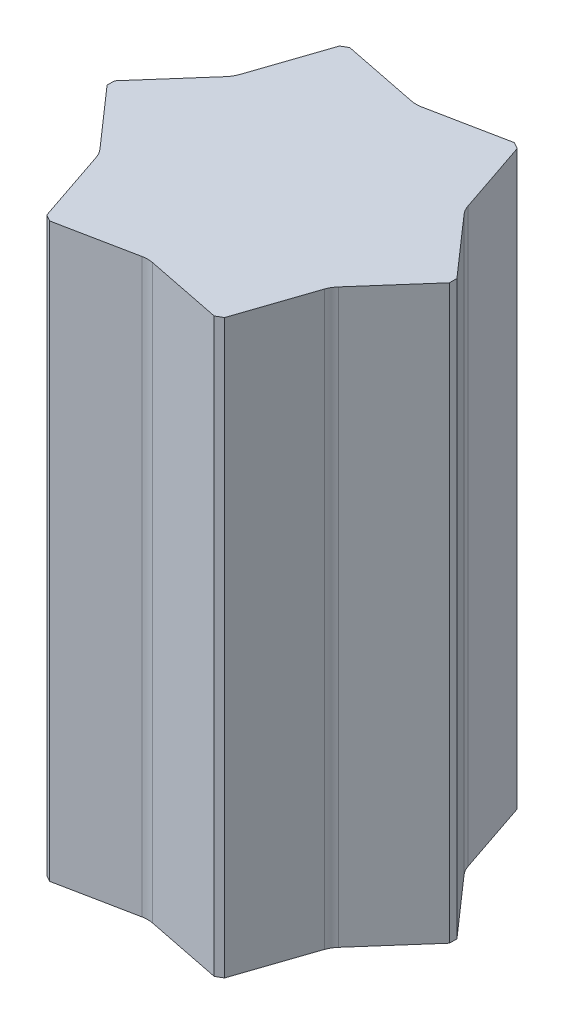
from build123d import *

# Parameters (mm, degrees)
EXTRUDE_1_DEPTH          = 660
CUT_EXTRUDE_1_DEPTH      = 661
CUT_EXTRUDE_1_DEPTH_BACK = 661
SHELL_1_T                = 10


with BuildPart() as part:
    # 草图1 → 凸台-拉伸1 (new body, symmetric)
    with BuildSketch(Plane(origin=(0, 0, 0), x_dir=(1, 0, 0), z_dir=(0, 1, 0))):
        Polygon((395, 8.660254038), (205, 337.749907476), (190, 346.410161514), (-190, 346.410161514), (-205, 337.749907476), (-395, 8.660254038), (-395, -8.660254038), (-205, -337.749907476), (-190, -346.410161514), (190, -346.410161514), (205, -337.749907476), (395, -8.660254038), align=None)
    extrude(amount=EXTRUDE_1_DEPTH, both=True)

    # 草图4 → 切除-拉伸1 (cut, two sides)
    with BuildSketch(Plane(origin=(0, 0, 0), x_dir=(1, 0, 0), z_dir=(0, 1, 0))) as cut_extrude_1_sk:
        with BuildLine():
            Line((190, 369.620348729), (190, 346.410161514))
            Line((190, 346.410161514), (11.76, 310.784114995))
            ThreePointArc((11.76, 310.784114995), (0, 309.620348729), (-11.76, 310.784114995))
            Line((-11.76, 310.784114995), (-190, 346.410161514))
            Line((-190, 346.410161514), (-190, 369.620348729))
            Line((-190, 369.620348729), (-190, 392.830535944))
            Line((-190, 392.830535944), (-11.76, 428.456582463))
            ThreePointArc((-11.76, 428.456582463), (0, 429.620348729), (11.76, 428.456582463))
            Line((11.76, 428.456582463), (190, 392.830535944))
            Line((190, 392.830535944), (190, 369.620348729))
        make_face()
        with BuildLine():
            Line((415.100611755, 20.265347645), (395, 8.660254038))
            Line((395, 8.660254038), (275.026938678, 145.207598749))
            ThreePointArc((275.026938678, 145.207598749), (268.139087528, 154.810174364), (263.266938678, 165.576516246))
            Line((263.266938678, 165.576516246), (205, 337.749907476))
            Line((205, 337.749907476), (225.100611755, 349.355001084))
            Line((225.100611755, 349.355001084), (245.20122351, 360.960094691))
            Line((245.20122351, 360.960094691), (365.174284832, 224.41274998))
            ThreePointArc((365.174284832, 224.41274998), (372.062135982, 214.810174364), (376.934284832, 204.043832483))
            Line((376.934284832, 204.043832483), (435.20122351, 31.870441253))
            Line((435.20122351, 31.870441253), (415.100611755, 20.265347645))
        make_face()
        with BuildLine():
            Line((225.100611755, -349.355001084), (205, -337.749907476))
            Line((205, -337.749907476), (263.266938678, -165.576516246))
            ThreePointArc((263.266938678, -165.576516246), (268.139087528, -154.810174364), (275.026938678, -145.207598749))
            Line((275.026938678, -145.207598749), (395, -8.660254038))
            Line((395, -8.660254038), (415.100611755, -20.265347645))
            Line((415.100611755, -20.265347645), (435.20122351, -31.870441253))
            Line((435.20122351, -31.870441253), (376.934284832, -204.043832483))
            ThreePointArc((376.934284832, -204.043832483), (372.062135982, -214.810174364), (365.174284832, -224.41274998))
            Line((365.174284832, -224.41274998), (245.20122351, -360.960094691))
            Line((245.20122351, -360.960094691), (225.100611755, -349.355001084))
        make_face()
        with BuildLine():
            Line((-190, -369.620348729), (-190, -346.410161514))
            Line((-190, -346.410161514), (-11.76, -310.784114995))
            ThreePointArc((-11.76, -310.784114995), (0, -309.620348729), (11.76, -310.784114995))
            Line((11.76, -310.784114995), (190, -346.410161514))
            Line((190, -346.410161514), (190, -369.620348729))
            Line((190, -369.620348729), (190, -392.830535944))
            Line((190, -392.830535944), (11.76, -428.456582463))
            ThreePointArc((11.76, -428.456582463), (0, -429.620348729), (-11.76, -428.456582463))
            Line((-11.76, -428.456582463), (-190, -392.830535944))
            Line((-190, -392.830535944), (-190, -369.620348729))
        make_face()
        with BuildLine():
            Line((-415.100611755, -20.265347645), (-395, -8.660254038))
            Line((-395, -8.660254038), (-275.026938678, -145.207598749))
            ThreePointArc((-275.026938678, -145.207598749), (-268.139087528, -154.810174364), (-263.266938678, -165.576516246))
            Line((-263.266938678, -165.576516246), (-205, -337.749907476))
            Line((-205, -337.749907476), (-225.100611755, -349.355001084))
            Line((-225.100611755, -349.355001084), (-245.20122351, -360.960094691))
            Line((-245.20122351, -360.960094691), (-365.174284832, -224.41274998))
            ThreePointArc((-365.174284832, -224.41274998), (-372.062135982, -214.810174364), (-376.934284832, -204.043832483))
            Line((-376.934284832, -204.043832483), (-435.20122351, -31.870441253))
            Line((-435.20122351, -31.870441253), (-415.100611755, -20.265347645))
        make_face()
        with BuildLine():
            Line((-225.100611755, 349.355001084), (-205, 337.749907476))
            Line((-205, 337.749907476), (-263.266938678, 165.576516246))
            ThreePointArc((-263.266938678, 165.576516246), (-268.139087528, 154.810174364), (-275.026938678, 145.207598749))
            Line((-275.026938678, 145.207598749), (-395, 8.660254038))
            Line((-395, 8.660254038), (-415.100611755, 20.265347645))
            Line((-415.100611755, 20.265347645), (-435.20122351, 31.870441253))
            Line((-435.20122351, 31.870441253), (-376.934284832, 204.043832483))
            ThreePointArc((-376.934284832, 204.043832483), (-372.062135982, 214.810174364), (-365.174284832, 224.41274998))
            Line((-365.174284832, 224.41274998), (-245.20122351, 360.960094691))
            Line((-245.20122351, 360.960094691), (-225.100611755, 349.355001084))
        make_face()
    extrude(amount=CUT_EXTRUDE_1_DEPTH, mode=Mode.SUBTRACT)
    extrude(cut_extrude_1_sk.sketch, amount=-CUT_EXTRUDE_1_DEPTH_BACK, mode=Mode.SUBTRACT)

    # 抽壳1 (no face opened: a closed hollow body)
    add(offset(amount=-SHELL_1_T, mode=Mode.PRIVATE), mode=Mode.SUBTRACT)


solid = part.part
